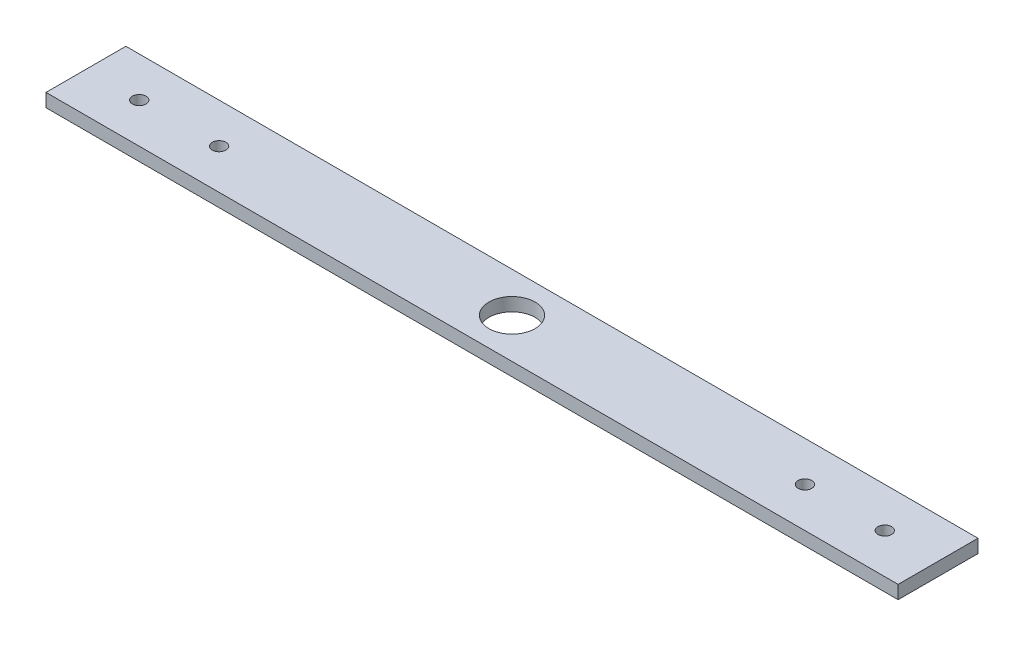
from build123d import *

# Parameters (mm, degrees)
SKETCH1_W                = 406.4
SKETCH1_H                = 38.1
BOSS_EXTRUDE1_DEPTH      = 6.35
SKETCH2_R                = 11
CUT_EXTRUDE1_DEPTH       = 7.62
F_0_257_DIAMETER_HOLE1_D = 6.5278


with BuildPart() as part:
    # Sketch1 → Boss-Extrude1 (new body)
    with BuildSketch(Plane(origin=(0, 0, 0), x_dir=(1, 0, 0), z_dir=(0, 1, 0))):
        Rectangle(SKETCH1_W, SKETCH1_H)
    extrude(amount=BOSS_EXTRUDE1_DEPTH)

    # Sketch2 → Cut-Extrude1 (cut)
    with BuildSketch(Plane(origin=(0, 6.35, 0), x_dir=(1, 0, 0), z_dir=(0, 1, 0))):
        Circle(SKETCH2_R)
    extrude(amount=-CUT_EXTRUDE1_DEPTH, mode=Mode.SUBTRACT)

    # F (0.257) Diameter Hole1 (through all)
    with Locations(Plane(origin=(0, 6.35, 0), x_dir=(1, 0, 0), z_dir=(0, 1, 0))):
        with Locations((177.8, 0), (139.7, 0)):
            f_0_257_diameter_hole1 = Hole(F_0_257_DIAMETER_HOLE1_D / 2)

    # Mirror1: F (0.257) Diameter Hole1 across plane
    add(f_0_257_diameter_hole1.mirror(Plane(origin=(0, 0, 0), x_dir=(0, 0, 1), z_dir=(1, 0, 0))), mode=Mode.SUBTRACT)


solid = part.part
